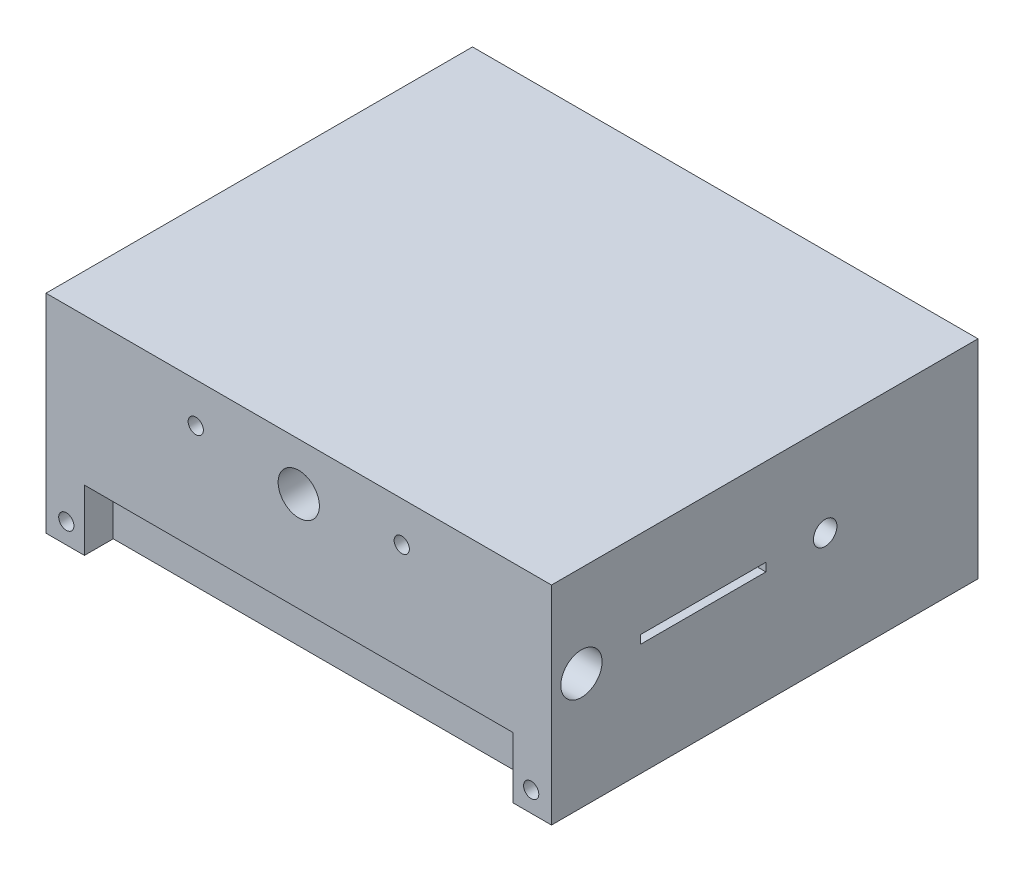
from build123d import *

# Parameters (mm, degrees)
SKETCH1_W           = 266.7
SKETCH1_H           = 130.0068901
BOSS_EXTRUDE1_DEPTH = 316.09292636
SKETCH2_R           = 4.7625
SKETCH2_R_2         = 12.8984375
CUT_EXTRUDE1_DEPTH  = 266.7
SKETCH3_R           = 12.8984375
SKETCH3_R_2         = 7.3421875
SKETCH3_W           = 78.287500016
SKETCH3_H           = 5.262500016
CUT_EXTRUDE2_DEPTH  = 332.74
SKETCH4_W           = 267.993719028
SKETCH4_H           = 38.1
CUT_EXTRUDE3_DEPTH  = 18.000000068


with BuildPart() as part:
    # Sketch1 → Boss-Extrude1 (new body)
    with BuildSketch(Plane(origin=(0, 0, 0), x_dir=(0, 0, -1), z_dir=(1, 0, 0))):
        Rectangle(SKETCH1_W, SKETCH1_H)
    extrude(amount=BOSS_EXTRUDE1_DEPTH)

    # Sketch2 → Cut-Extrude1 (cut)
    with BuildSketch(Plane.XY.offset(133.35)):
        with Locations((93.639440102, 39.990297972)):
            Circle(SKETCH2_R)
        with Locations((222.453486258, 39.990297972)):
            Circle(SKETCH2_R)
        with Locations((303.39292636, -52.30344505)):
            Circle(SKETCH2_R)
        with Locations((12.7, -52.30344505)):
            Circle(SKETCH2_R)
        with Locations((158.04646318, 35.218991284)):
            Circle(SKETCH2_R_2)
    extrude(amount=-CUT_EXTRUDE1_DEPTH, mode=Mode.SUBTRACT)

    # Sketch3 → Cut-Extrude2 (cut)
    with BuildSketch(Plane(origin=(316.09292636, 0, 0), x_dir=(0, 0, -1), z_dir=(1, 0, 0))):
        with Locations((-114.617463678, 7.67564505)):
            Circle(SKETCH3_R)
        with Locations((37.782536322, 7.67564505)):
            Circle(SKETCH3_R_2)
        with Locations((-38.4175, 7.67564505)):
            Rectangle(SKETCH3_W, SKETCH3_H)
    extrude(amount=-CUT_EXTRUDE2_DEPTH, mode=Mode.SUBTRACT)

    # Sketch4 → Cut-Extrude3 (cut)
    with BuildSketch(Plane.XY.offset(133.35)):
        with Locations((158.04646318, -45.95344505)):
            Rectangle(SKETCH4_W, SKETCH4_H)
    cut_extrude3 = extrude(amount=-CUT_EXTRUDE3_DEPTH, mode=Mode.SUBTRACT)

    # Mirror1: Cut-Extrude3 across plane
    add(cut_extrude3.mirror(Plane.XY), mode=Mode.SUBTRACT)


solid = part.part
